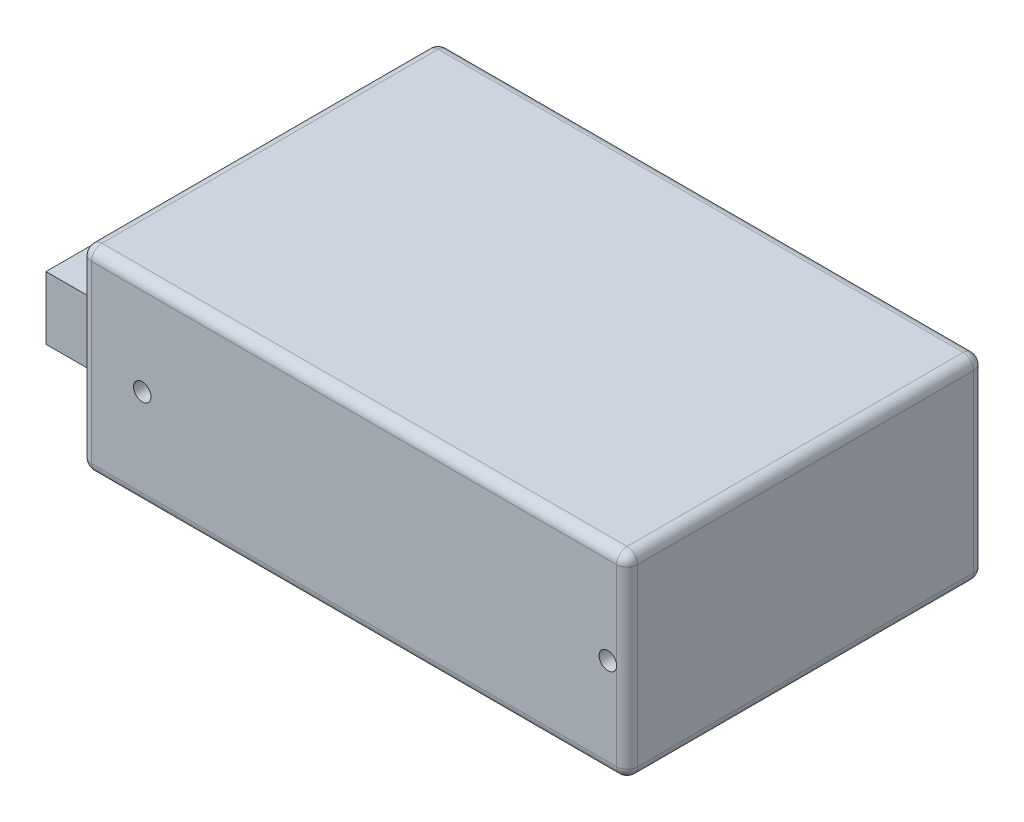
from build123d import *

# Parameters (mm, degrees)
SKETCH2_W           = 78
SKETCH2_H           = 51.00000000000001
BOSS_EXTRUDE1_DEPTH = 28
SKETCH3_W           = 40
SKETCH3_H           = 9.000000000000002
BOSS_EXTRUDE2_DEPTH = 14
FILLET1_R           = 1.5


with BuildPart() as part:
    # Sketch2 → Boss-Extrude1 (new body)
    with BuildSketch(Plane(origin=(0, 0, 0), x_dir=(1, 0, 0), z_dir=(0, 1, 0))):
        Rectangle(SKETCH2_W, SKETCH2_H)
    extrude(amount=BOSS_EXTRUDE1_DEPTH)

    # Sketch5 → Tap Drill for M3 Tap1 (revolve, cut)
    with BuildSketch(Plane(origin=(-26.499999999999996, 0, 0.0999999999999994), x_dir=(0, 0, -1), z_dir=(1, 0, 0))):
        Polygon((0, 0), (-1.9e-15, 7.751075773784449), (1.2499999999999876, 7.000000000000006), (1.249999999999989, -1.4e-15), align=None)
    revolve(axis=Axis((-26.499999999999996, -6.349999999999991, 0.0999999999999994), (0, 1, 0)), mode=Mode.SUBTRACT)

    # Sketch5 at point 2 (carried to point 2, square into its face) → Tap Drill for M3 Tap1 at 2 (revolve, cut)
    with BuildSketch(Plane(origin=(28.5, 0, 0.1), x_dir=(0, 0, -1), z_dir=(1, 0, 0))):
        Polygon((0, 0), (-1.9e-15, 7.751075773784449), (1.2499999999999876, 7.000000000000006), (1.249999999999989, -1.4e-15), align=None)
    revolve(axis=Axis((28.5, -6.35, 0.1), (0, 1, 0)), mode=Mode.SUBTRACT)

    # Sketch5 at point 3 (carried to point 3, square into its face) → Tap Drill for M3 Tap1 at 3 (revolve, cut)
    with BuildSketch(Plane(origin=(-30.25, 14, 25.5), x_dir=(0, -1, 0), z_dir=(1, 0, 0))):
        Polygon((0, 0), (-1.9e-15, 7.751075773784449), (1.2499999999999876, 7.000000000000006), (1.249999999999989, -1.4e-15), align=None)
    revolve(axis=Axis((-30.25, 14, 31.85), (0, 0, -1)), mode=Mode.SUBTRACT)

    # Sketch5 at point 4 (carried to point 4, square into its face) → Tap Drill for M3 Tap1 at 4 (revolve, cut)
    with BuildSketch(Plane(origin=(36.25, 14, 25.5), x_dir=(0, -1, 0), z_dir=(1, 0, 0))):
        Polygon((0, 0), (-1.9e-15, 7.751075773784449), (1.2499999999999876, 7.000000000000006), (1.249999999999989, -1.4e-15), align=None)
    revolve(axis=Axis((36.25, 14, 31.85), (0, 0, -1)), mode=Mode.SUBTRACT)

    # Fillet1
    fillet1_edges = [part.edges().sort_by_distance(p)[0] for p in [
        (-38.99999999999999, 28, 0),
        (7.11e-15, 28, 25.5),
        (39.00000000000001, 28, 0),
        (7.11e-15, 0, 25.5),
        (-38.99999999999999, 0, 0),
        (7.11e-15, 0, -25.5),
        (39.00000000000001, 0, 0),
        (39.00000000000001, 14, 25.5),
        (-38.99999999999999, 14, 25.5),
        (-38.99999999999999, 14, -25.5),
        (39.00000000000001, 14, -25.5),
        (7.11e-15, 28, -25.5),
    ]]
    fillet(fillet1_edges, radius=FILLET1_R)


with BuildPart() as body_2:
    # Sketch3 → Boss-Extrude2 (new body)
    with BuildSketch(Plane.ZY.offset(38.99999999999999)):
        with Locations((-3.5, 8.5)):
            Rectangle(SKETCH3_W, SKETCH3_H)
    extrude(amount=BOSS_EXTRUDE2_DEPTH)


solid = Compound([part.part, body_2.part])
